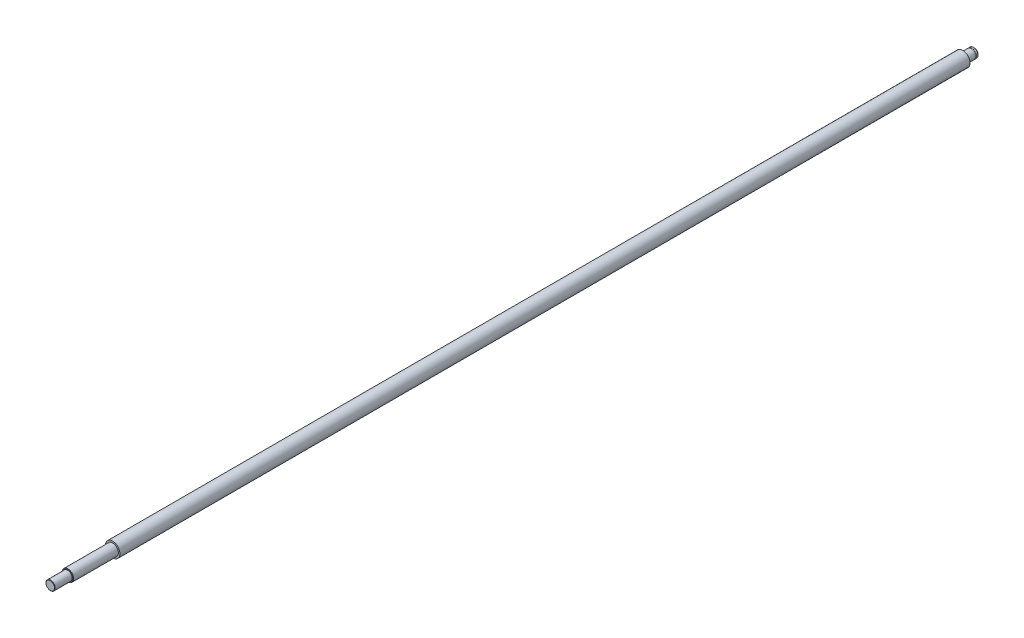
from build123d import *

# Parameters (mm, degrees)
SKETCH2_W     = 0.9
SKETCH2_H     = 0.2
CHAMFER1_SIZE = 0.8
CHAMFER2_SIZE = 0.3


with BuildPart() as part:
    # Sketch1 → Revolve1 (revolve)
    with BuildSketch(Plane(origin=(0, 0, 0), x_dir=(0, 0, -1), z_dir=(1, 0, 0))):
        Polygon((-400, 0), (400, 0), (400, 4), (390, 4), (390, 6.32), (-346, 6.32), (-346, 4.94), (-385, 4.94), (-385, 4), (-400, 4), align=None)
    revolve(axis=Axis((0, 0, 400), (0, 0, -1)))

    # Sketch2 → Cut-Revolve1 (revolve, cut)
    with BuildSketch(Plane(origin=(0, 0, 0), x_dir=(0, 0, -1), z_dir=(1, 0, 0))):
        with Locations((397.45, 3.9)):
            Rectangle(SKETCH2_W, SKETCH2_H)
    revolve(axis=Axis((0, 0, -400), (0, 0, 1)), mode=Mode.SUBTRACT)

    # Chamfer1
    chamfer1_edges = [part.edges().sort_by_distance(p)[0] for p in [
        (0, -4, -400),
    ]]
    chamfer(chamfer1_edges, length=CHAMFER1_SIZE)

    # Chamfer2
    chamfer2_edges = [part.edges().sort_by_distance(p)[0] for p in [
        (0, -4.94, 385),
        (0, -4, 400),
    ]]
    chamfer(chamfer2_edges, length=CHAMFER2_SIZE)


solid = part.part
